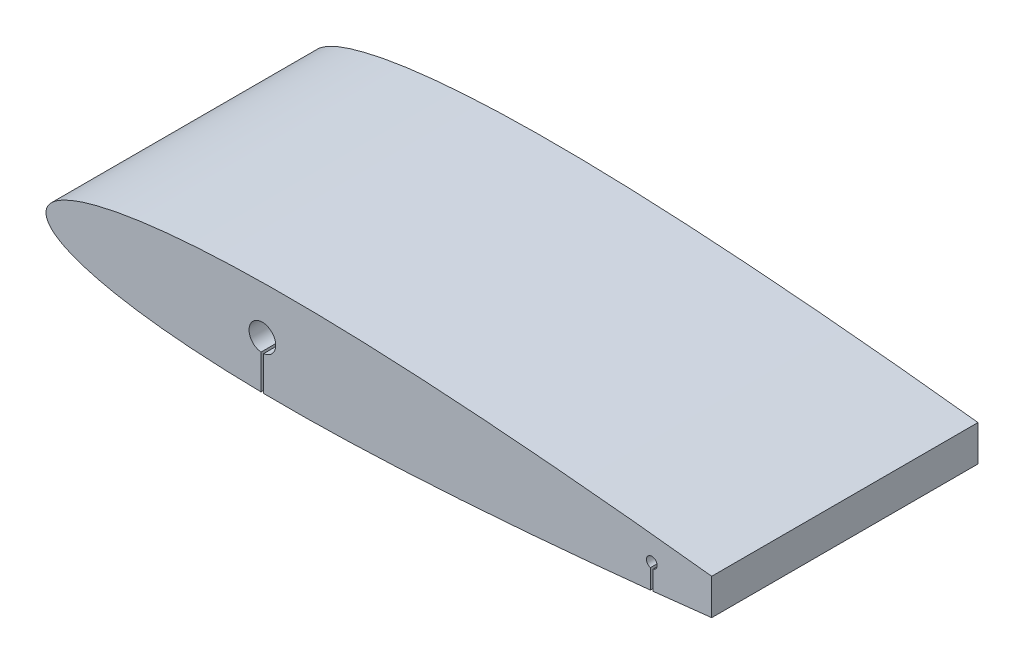
from build123d import *

# Parameters (mm, degrees)
BOSS_EXTRUDE1_DEPTH      = 50
SKETCH7_R                = 5
SKETCH7_R_2              = 2
CUT_EXTRUDE7_DEPTH       = 305.670524863
CUT_EXTRUDE7_DEPTH_BACK  = 305.670524863
SKETCH9_W                = 50
SKETCH9_H                = 100
CUT_EXTRUDE8_DEPTH       = 305.670524863
CUT_EXTRUDE8_DEPTH_BACK  = 305.670524863
SKETCH11_W               = 44.16
SKETCH11_H               = 34.63
CUT_EXTRUDE10_DEPTH      = 256.898724687
SKETCH12_W               = 1
SKETCH12_H               = 18.003573168
CUT_EXTRUDE11_DEPTH      = 256.585853893
CUT_EXTRUDE11_DEPTH_BACK = 256.585853893


with BuildPart() as part:
    # Sketch5 → Boss-Extrude1 (new, symmetric)
    with BuildSketch(Plane.XY):
        with BuildLine():
            Line((300, 0.378000086), (300, -0.378000086))
            add(Edge.make_bspline(
                [(300, 0.378000086), (299.270406258, 0.47944593), (297.234666467, 0.762503927), (293.659648722, 1.257673791), (289.112409325, 1.874242868), (284.080813047, 2.544518018), (278.752039398, 3.238123051), (273.265892957, 3.934947328), (267.705948145, 4.629020993), (262.114554424, 5.313070312), (256.508339042, 5.98219317), (250.891727853, 6.637992315), (245.269544548, 7.281780887), (239.647331656, 7.912234559), (234.025115138, 8.526993981), (228.399071658, 9.126231834), (222.768240123, 9.71307981), (217.135901993, 10.287462144), (211.505390076, 10.846943545), (205.877598449, 11.391645411), (200.251489743, 11.920887329), (194.626396629, 12.434619899), (189.002771954, 12.931914743), (183.381504479, 13.413100625), (177.763197883, 13.876379849), (172.148272526, 14.321240443), (166.537499181, 14.747824264), (160.931704642, 15.154231582), (155.331676028, 15.539104381), (149.737504253, 15.902653172), (144.148652919, 16.241849804), (138.565642978, 16.557424303), (132.990821912, 16.847401378), (127.427400287, 17.110215561), (121.877579225, 17.343895653), (116.340716908, 17.545260794), (110.81543346, 17.712683139), (105.301229225, 17.844501987), (99.800524694, 17.940095883), (94.317389178, 17.996594522), (88.855716162, 18.010128544), (83.418598836, 17.979237919), (78.008430461, 17.899164774), (72.628403778, 17.767037818), (67.282685946, 17.579417922), (61.977310891, 17.331519421), (56.72063582, 17.021036513), (51.525118947, 16.640961845), (46.408145083, 16.190192264), (41.394117392, 15.661672653), (36.515611307, 15.053967199), (31.818948595, 14.365626864), (27.366102973, 13.60347877), (23.235155161, 12.782586344), (19.502578811, 11.920253456), (16.218207008, 11.044600302), (13.389120989, 10.175078564), (10.984863761, 9.333500833), (8.961495446, 8.522064815), (7.267225637, 7.746977759), (5.845985727, 7.010627212), (4.647644075, 6.300635462), (3.62816801, 5.60651494), (2.751841757, 4.926636369), (2.006189751, 4.249918223), (1.390518388, 3.570260302), (0.900932575, 2.890942908), (0.52920759, 2.220219777), (0.260411531, 1.566459291), (0.085644609, 0.931036139), (-0.003577313, 0.308981085), (-0.003577313, -0.308981085), (0.085644609, -0.931036139), (0.260411531, -1.566459291), (0.52920759, -2.220219777), (0.900932575, -2.890942908), (1.390518388, -3.570260302), (2.006189751, -4.249918223), (2.751841757, -4.926636369), (3.62816801, -5.60651494), (4.647644075, -6.300635462), (5.845985727, -7.010627213), (7.267225637, -7.746977757), (8.961495444, -8.522064829), (10.984863772, -9.333500769), (13.389120938, -10.175078867), (16.218207245, -11.044598882), (19.502577721, -11.920259984), (23.235160006, -12.782557313), (27.366065703, -13.603599247), (31.819014163, -14.365116623), (36.515574857, -15.054109513), (41.394123531, -15.66163244), (46.408143388, -16.190203367), (51.525119412, -16.640958803), (56.720635693, -17.021037342), (61.977310926, -17.331519196), (67.282685937, -17.579417983), (72.628403781, -17.767037802), (78.008430461, -17.899164778), (83.418598837, -17.979237918), (88.855716162, -18.010128544), (94.317389178, -17.996594522), (99.800524694, -17.940095883), (105.301229225, -17.844501987), (110.81543346, -17.712683139), (116.340716908, -17.545260794), (121.877579225, -17.343895653), (127.427400287, -17.110215561), (132.990821912, -16.847401378), (138.565642978, -16.557424303), (144.148652919, -16.241849804), (149.737504253, -15.902653172), (155.331676028, -15.539104381), (160.931704642, -15.154231582), (166.537499181, -14.747824264), (172.148272526, -14.321240443), (177.763197883, -13.876379849), (183.381504479, -13.413100625), (189.002771954, -12.931914743), (194.626396629, -12.434619899), (200.251489743, -11.920887329), (205.877598449, -11.391645411), (211.505390076, -10.846943545), (217.135901993, -10.287462144), (222.768240123, -9.71307981), (228.399071658, -9.126231834), (234.025115138, -8.526993981), (239.647331656, -7.912234559), (245.269544548, -7.281780887), (250.891727853, -6.637992315), (256.508339042, -5.98219317), (262.114554424, -5.313070312), (267.705948145, -4.629020993), (273.265892957, -3.934947328), (278.752039398, -3.238123051), (284.080813047, -2.544518018), (289.112409325, -1.874242868), (293.659648722, -1.257673791), (297.234666467, -0.762503927), (299.270406258, -0.47944593), (300, -0.378000086)],
                knots=[0, 0, 0, 0, 0.003612221, 0.010078953, 0.017698618, 0.026115111, 0.034970966, 0.04405038, 0.05323433, 0.06244757, 0.071673993, 0.080921319, 0.090177538, 0.099424342, 0.108664441, 0.117912199, 0.127169502, 0.136426595, 0.145675426, 0.154916495, 0.164153237, 0.173386649, 0.182615736, 0.191838089, 0.201053134, 0.210260393, 0.219458942, 0.228646747, 0.237822316, 0.246985224, 0.256137384, 0.265279416, 0.27440695, 0.283512193, 0.292591781, 0.301646285, 0.310681793, 0.319699068, 0.32869452, 0.33766016, 0.346588583, 0.355477412, 0.364322937, 0.373121614, 0.381867635, 0.390553005, 0.399166026, 0.407689628, 0.416098119, 0.424354887, 0.432412429, 0.440204728, 0.447630505, 0.454563638, 0.460855379, 0.466413319, 0.47122861, 0.475365774, 0.47890126, 0.481915077, 0.484498872, 0.486747127, 0.488741252, 0.490543179, 0.492182104, 0.493672831, 0.495031908, 0.49627906, 0.497424737, 0.498490166, 0.499502758, 0.500497254, 0.501509846, 0.502575275, 0.503720952, 0.504968104, 0.506327181, 0.507817908, 0.509456832, 0.51125876, 0.513252884, 0.51550114, 0.518084934, 0.521098752, 0.524634237, 0.528771401, 0.533586692, 0.539144632, 0.545436374, 0.552369506, 0.5597952, 0.567587571, 0.575645113, 0.583901881, 0.592310372, 0.600833974, 0.609446995, 0.618132365, 0.626878386, 0.635677063, 0.644522588, 0.653411417, 0.66233984, 0.67130548, 0.680300932, 0.689318207, 0.698353715, 0.707408219, 0.716487807, 0.72559305, 0.734720584, 0.743862616, 0.753014776, 0.762177684, 0.771353253, 0.780541058, 0.789739607, 0.798946866, 0.808161911, 0.817384264, 0.826613351, 0.835846763, 0.845083505, 0.854324574, 0.863573405, 0.872830498, 0.882087801, 0.891335559, 0.900575658, 0.909822462, 0.919078681, 0.928326007, 0.93755243, 0.94676567, 0.95594962, 0.965029034, 0.973884889, 0.982301382, 0.989921047, 0.996387779, 1, 1, 1, 1], degree=3))
        make_face()
    extrude(amount=BOSS_EXTRUDE1_DEPTH, both=True)

    # Sketch7 → Cut-Extrude7 (cut, two sides)
    with BuildSketch(Plane.XY) as cut_extrude7_sk:
        with Locations((81.25, 0)):
            Circle(SKETCH7_R)
        with Locations((227.5, 0)):
            Circle(SKETCH7_R_2)
    extrude(amount=CUT_EXTRUDE7_DEPTH, mode=Mode.SUBTRACT)
    extrude(cut_extrude7_sk.sketch, amount=-CUT_EXTRUDE7_DEPTH_BACK, mode=Mode.SUBTRACT)

    # Sketch9 → Cut-Extrude8 (cut, two sides)
    with BuildSketch(Plane(origin=(0, 0, 0), x_dir=(1, 0, 0), z_dir=(0, 1, 0))) as cut_extrude8_sk:
        with Locations((275, 0)):
            Rectangle(SKETCH9_W, SKETCH9_H)
    extrude(amount=CUT_EXTRUDE8_DEPTH, mode=Mode.SUBTRACT)
    extrude(cut_extrude8_sk.sketch, amount=-CUT_EXTRUDE8_DEPTH_BACK, mode=Mode.SUBTRACT)

    # Sketch11 → Cut-Extrude10 (cut, through all)
    with BuildSketch(Plane(origin=(0, -4, 0), x_dir=(1, 0, 0), z_dir=(0, 1, 0))):
        with Locations((185.42, 0)):
            Rectangle(SKETCH11_W, SKETCH11_H)
    extrude(amount=-CUT_EXTRUDE10_DEPTH, mode=Mode.SUBTRACT)

    # Sketch12 → Cut-Extrude11 (cut, two sides)
    with BuildSketch(Plane.XY) as cut_extrude11_sk:
        with Locations((81.25, -9.001786584)):
            Rectangle(SKETCH12_W, SKETCH12_H)
        with Locations((227.5, -9.001786584)):
            Rectangle(SKETCH12_W, SKETCH12_H)
    extrude(amount=CUT_EXTRUDE11_DEPTH, mode=Mode.SUBTRACT)
    extrude(cut_extrude11_sk.sketch, amount=-CUT_EXTRUDE11_DEPTH_BACK, mode=Mode.SUBTRACT)


solid = part.part
